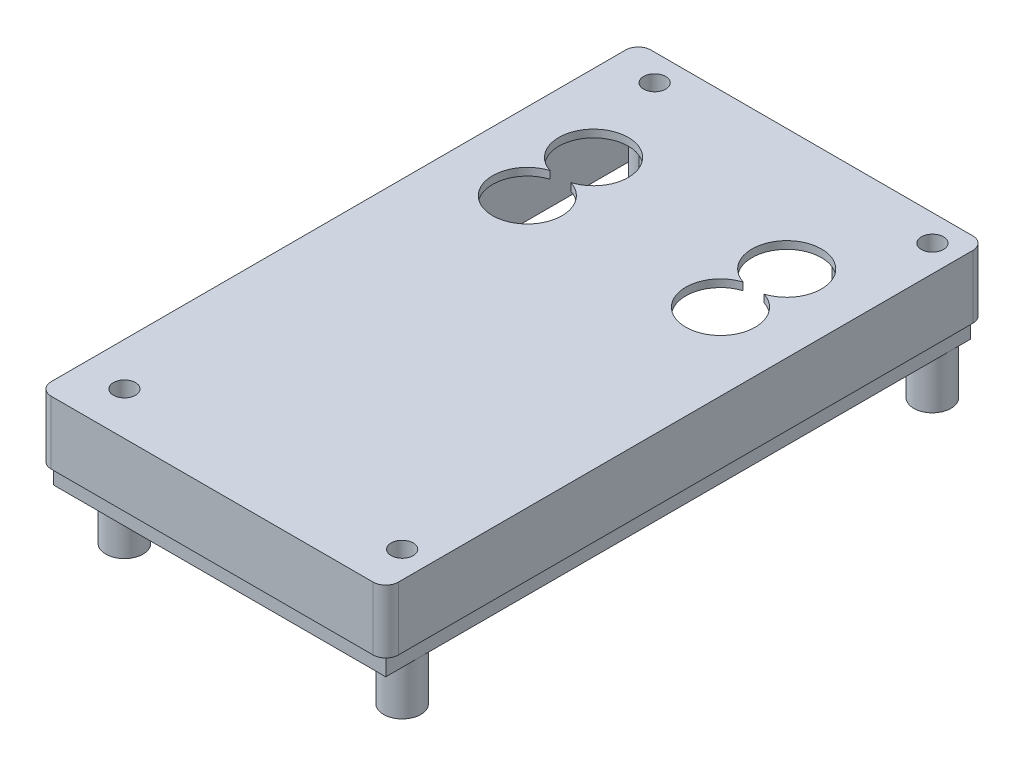
from build123d import *

# Parameters (mm, degrees)
SKETCH1_W           = 55
SKETCH1_H           = 95
BOSS_EXTRUDE1_DEPTH = 10
SKETCH3_W           = 52.6
SKETCH3_H           = 92.6
CUT_EXTRUDE1_DEPTH  = 8.8
FILLET1_R           = 2
CUT_EXTRUDE2_REACH  = 12
SKETCH4_R           = 5.5
CUT_EXTRUDE3_REACH  = 12
SKETCH5_R           = 5.5
SKETCH7_R           = 2.95
BOSS_EXTRUDE4_DEPTH = 20
CUT_EXTRUDE4_REACH  = 23.2
SKETCH8_R           = 1.75
BOSS_EXTRUDE5_DEPTH = 12
SKETCH11_R          = 2
BOSS_EXTRUDE6_DEPTH = 10
SKETCH12_R          = 0.75
CUT_EXTRUDE5_DEPTH  = 7


with BuildPart() as part:
    # Sketch1 → Boss-Extrude1 (new body)
    with BuildSketch(Plane(origin=(0, 0, 0), x_dir=(1, 0, 0), z_dir=(0, 1, 0))):
        with Locations((27.5, -47.5)):
            Rectangle(SKETCH1_W, SKETCH1_H)
    extrude(amount=-BOSS_EXTRUDE1_DEPTH)

    # Sketch3 → Cut-Extrude1 (cut)
    with BuildSketch(Plane.XZ.offset(10)):
        with Locations((27.5, 47.5)):
            Rectangle(SKETCH3_W, SKETCH3_H)
    extrude(amount=-CUT_EXTRUDE1_DEPTH, mode=Mode.SUBTRACT)

    # Fillet1
    fillet1_edges = [part.edges().sort_by_distance(p)[0] for p in [
        (0, -5, 0),
        (0, -5, 95),
        (55, -5, 95),
        (55, -5, 0),
    ]]
    fillet(fillet1_edges, radius=FILLET1_R)

    # Sketch4 → Cut-Extrude2 (cut, up to next)
    with BuildSketch(Plane(origin=(0, 0, 0), x_dir=(1, 0, 0), z_dir=(0, 1, 0)), mode=Mode.PRIVATE) as cut_extrude2_sk1:
        with Locations((42.8, -29.77)):
            Circle(SKETCH4_R)
    cut_extrude2_tool1 = extrude(cut_extrude2_sk1.sketch, amount=-CUT_EXTRUDE2_REACH, mode=Mode.PRIVATE) & part.part
    add(cut_extrude2_tool1.solids().sort_by_distance((42.8, 0, 29.77))[0], mode=Mode.SUBTRACT)
    # Sketch4 → Cut-Extrude2 (cut, up to next)
    with BuildSketch(Plane(origin=(0, 0, 0), x_dir=(1, 0, 0), z_dir=(0, 1, 0)), mode=Mode.PRIVATE) as cut_extrude2_sk2:
        with Locations((42.8, -19.28)):
            Circle(SKETCH4_R)
    cut_extrude2_tool2 = extrude(cut_extrude2_sk2.sketch, amount=-CUT_EXTRUDE2_REACH, mode=Mode.PRIVATE) & part.part
    add(cut_extrude2_tool2.solids().sort_by_distance((42.8, 0, 19.28))[0], mode=Mode.SUBTRACT)

    # Sketch5 → Cut-Extrude3 (cut, up to next)
    with BuildSketch(Plane(origin=(0, 0, 0), x_dir=(1, 0, 0), z_dir=(0, 1, 0)), mode=Mode.PRIVATE) as cut_extrude3_sk1:
        with Locations((12.2, -29.77)):
            Circle(SKETCH5_R)
    cut_extrude3_tool1 = extrude(cut_extrude3_sk1.sketch, amount=-CUT_EXTRUDE3_REACH, mode=Mode.PRIVATE) & part.part
    add(cut_extrude3_tool1.solids().sort_by_distance((12.2, 0, 29.77))[0], mode=Mode.SUBTRACT)
    # Sketch5 → Cut-Extrude3 (cut, up to next)
    with BuildSketch(Plane(origin=(0, 0, 0), x_dir=(1, 0, 0), z_dir=(0, 1, 0)), mode=Mode.PRIVATE) as cut_extrude3_sk2:
        with Locations((12.2, -19.28)):
            Circle(SKETCH5_R)
    cut_extrude3_tool2 = extrude(cut_extrude3_sk2.sketch, amount=-CUT_EXTRUDE3_REACH, mode=Mode.PRIVATE) & part.part
    add(cut_extrude3_tool2.solids().sort_by_distance((12.2, 0, 19.28))[0], mode=Mode.SUBTRACT)

    # Sketch7 → Boss-Extrude4 (add)
    with BuildSketch(Plane.XZ.offset(1.2)):
        with Locations((50.8, 88.2)):
            Circle(SKETCH7_R)
        with Locations((6.8, 88.2)):
            Circle(SKETCH7_R)
        with Locations((6.8, 4.2)):
            Circle(SKETCH7_R)
        with Locations((50.8, 4.2)):
            Circle(SKETCH7_R)
    extrude(amount=BOSS_EXTRUDE4_DEPTH)

    # Sketch8 → Cut-Extrude4 (cut, up to next)
    with BuildSketch(Plane(origin=(0, 0, 0), x_dir=(1, 0, 0), z_dir=(0, 1, 0)), mode=Mode.PRIVATE) as cut_extrude4_sk1:
        with Locations((6.8, -88.2)):
            Circle(SKETCH8_R)
    cut_extrude4_tool1 = extrude(cut_extrude4_sk1.sketch, amount=-CUT_EXTRUDE4_REACH, mode=Mode.PRIVATE) & part.part
    add(cut_extrude4_tool1.solids().sort_by_distance((6.8, 0, 88.2))[0], mode=Mode.SUBTRACT)
    # Sketch8 → Cut-Extrude4 (cut, up to next)
    with BuildSketch(Plane(origin=(0, 0, 0), x_dir=(1, 0, 0), z_dir=(0, 1, 0)), mode=Mode.PRIVATE) as cut_extrude4_sk2:
        with Locations((50.8, -88.2)):
            Circle(SKETCH8_R)
    cut_extrude4_tool2 = extrude(cut_extrude4_sk2.sketch, amount=-CUT_EXTRUDE4_REACH, mode=Mode.PRIVATE) & part.part
    add(cut_extrude4_tool2.solids().sort_by_distance((50.8, 0, 88.2))[0], mode=Mode.SUBTRACT)
    # Sketch8 → Cut-Extrude4 (cut, up to next)
    with BuildSketch(Plane(origin=(0, 0, 0), x_dir=(1, 0, 0), z_dir=(0, 1, 0)), mode=Mode.PRIVATE) as cut_extrude4_sk3:
        with Locations((50.8, -4.2)):
            Circle(SKETCH8_R)
    cut_extrude4_tool3 = extrude(cut_extrude4_sk3.sketch, amount=-CUT_EXTRUDE4_REACH, mode=Mode.PRIVATE) & part.part
    add(cut_extrude4_tool3.solids().sort_by_distance((50.8, 0, 4.2))[0], mode=Mode.SUBTRACT)
    # Sketch8 → Cut-Extrude4 (cut, up to next)
    with BuildSketch(Plane(origin=(0, 0, 0), x_dir=(1, 0, 0), z_dir=(0, 1, 0)), mode=Mode.PRIVATE) as cut_extrude4_sk4:
        with Locations((6.8, -4.2)):
            Circle(SKETCH8_R)
    cut_extrude4_tool4 = extrude(cut_extrude4_sk4.sketch, amount=-CUT_EXTRUDE4_REACH, mode=Mode.PRIVATE) & part.part
    add(cut_extrude4_tool4.solids().sort_by_distance((6.8, 0, 4.2))[0], mode=Mode.SUBTRACT)

    # Sketch10 → Boss-Extrude5 (add)
    with BuildSketch(Plane.XZ.offset(1.2)):
        Polygon((1.2, 93.8), (1.2, 1.2), (16.2, 1.2), (16.2, 2.4), (2.4, 2.4), (2.4, 92.6), (52.6, 92.6), (52.6, 2.4), (38.8, 2.4), (38.8, 1.2), (53.8, 1.2), (53.8, 93.8), align=None)
    extrude(amount=BOSS_EXTRUDE5_DEPTH)

    # Sketch11 → Boss-Extrude6 (add)
    with BuildSketch(Plane.XZ.offset(1.2)):
        with Locations((12.2, 9.275)):
            Circle(SKETCH11_R)
        with Locations((42.8, 9.275)):
            Circle(SKETCH11_R)
        with Locations((12.2, 39.775)):
            Circle(SKETCH11_R)
        with Locations((42.8, 39.775)):
            Circle(SKETCH11_R)
    extrude(amount=BOSS_EXTRUDE6_DEPTH)

    # Sketch12 → Cut-Extrude5 (cut)
    with BuildSketch(Plane(origin=(0, -11.2, 0), x_dir=(-1, 0, 0), z_dir=(0, -1, 0))):
        with Locations((-42.8, -39.775)):
            Circle(SKETCH12_R)
        with Locations((-12.2, -39.775)):
            Circle(SKETCH12_R)
        with Locations((-42.8, -9.275)):
            Circle(SKETCH12_R)
        with Locations((-12.2, -9.275)):
            Circle(SKETCH12_R)
    extrude(amount=-CUT_EXTRUDE5_DEPTH, mode=Mode.SUBTRACT)


solid = part.part
